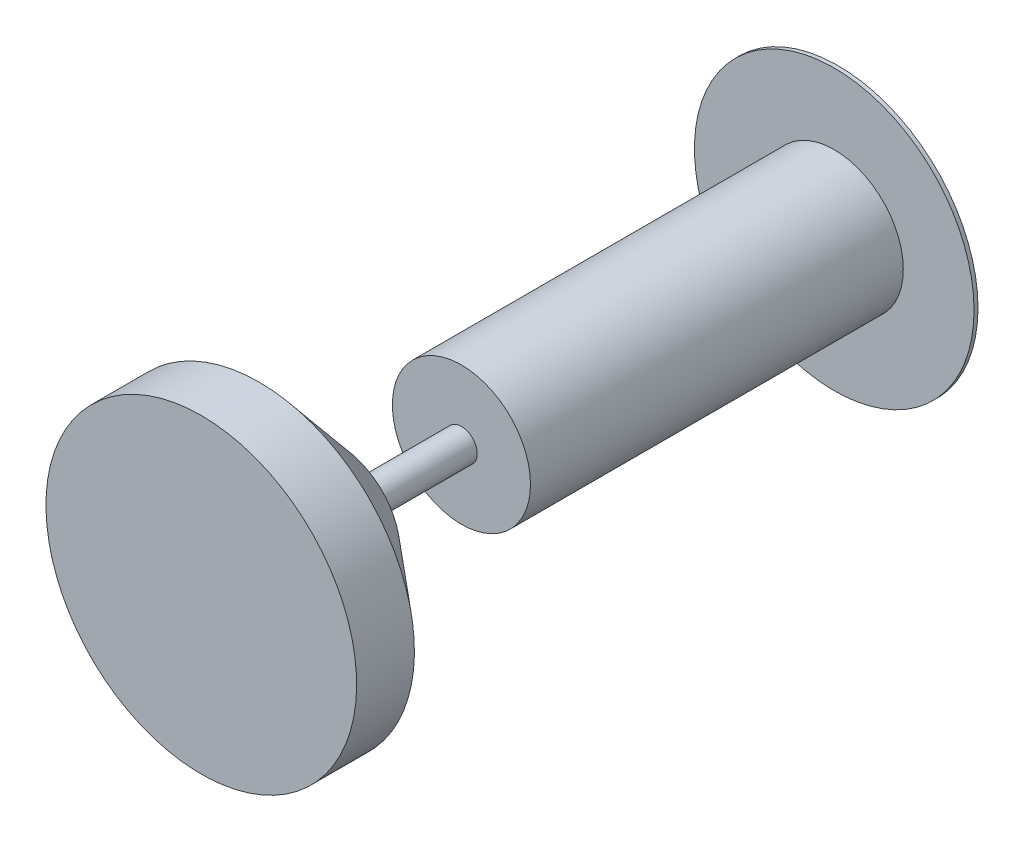
from build123d import *

# Parameters (mm, degrees)
SKETCH1_R                = 50.8
BOSS_EXTRUDE1_DEPTH      = 686.4
BOSS_EXTRUDE1_DEPTH_BACK = 1363.6
SKETCH2_R                = 450
BOSS_EXTRUDE2_DEPTH      = 12.7
SKETCH3_R                = 222.25
BOSS_EXTRUDE3_DEPTH      = 1200


with BuildPart() as part:
    # Sketch1 → Boss-Extrude1 (new body, two sides)
    with BuildSketch(Plane.XY) as boss_extrude1_sk:
        Circle(SKETCH1_R)
    extrude(amount=BOSS_EXTRUDE1_DEPTH)
    extrude(boss_extrude1_sk.sketch, amount=-BOSS_EXTRUDE1_DEPTH_BACK)

    # Sketch2 → Boss-Extrude2 (add)
    with BuildSketch(Plane.XY.offset(-1363.6)):
        Circle(SKETCH2_R)
    extrude(amount=BOSS_EXTRUDE2_DEPTH)

    # Sketch3 → Boss-Extrude3 (add)
    with BuildSketch(Plane.XY.offset(-1350.9)):
        Circle(SKETCH3_R)
    extrude(amount=BOSS_EXTRUDE3_DEPTH)

    # Sketch5 → Revolve1 (revolve)
    with BuildSketch(Plane(origin=(0, 0, 0), x_dir=(0, 0, -1), z_dir=(1, 0, 0))):
        Polygon((-686.4, 0), (-686.4, 500), (-500.4, 500), (-246.4, 200), (-246.4, 0), align=None)
    revolve(axis=Axis((0, 0, 246.4), (0, 0, 1)))


solid = part.part
